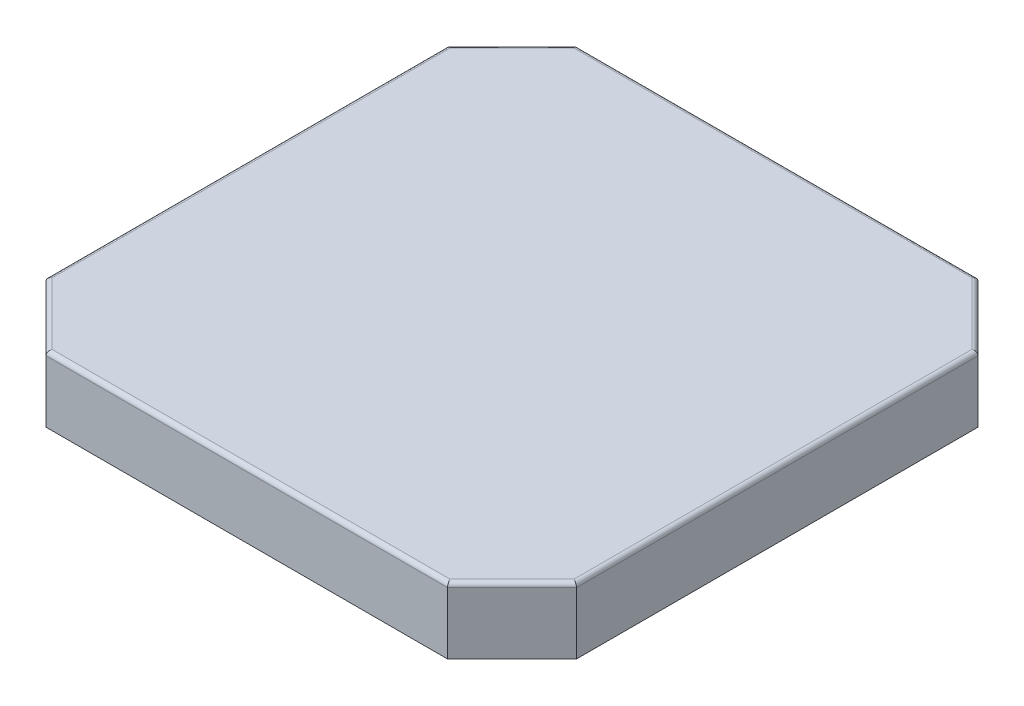
from build123d import *

# Parameters (mm, degrees)
ESQUISSE1_W             = 24.7
ESQUISSE1_H             = 24.7
BOSS_EXTRU_1_DEPTH      = 3.08
CHANFREIN1_SIZE         = 3
CONG_1_R                = 0.2
ESQUISSE2_W             = 6
ESQUISSE2_H             = 2.88
ENL_V_MAT_EXTRU_1_DEPTH = 22.08
ENL_V_MAT_EXTRU_2_DEPTH = 2.88


with BuildPart() as part:
    # Esquisse1 → Boss.-Extru.1 (new body)
    with BuildSketch(Plane(origin=(0, 0, 0), x_dir=(1, 0, 0), z_dir=(0, 1, 0))):
        with Locations((12.35, 12.35)):
            Rectangle(ESQUISSE1_W, ESQUISSE1_H)
    extrude(amount=BOSS_EXTRU_1_DEPTH)

    # Chanfrein1
    chanfrein1_edges = [part.edges().sort_by_distance(p)[0] for p in [
        (0, 1.54, -24.7),
        (24.7, 1.54, -24.7),
        (24.7, 1.54, 0),
        (0, 1.54, 0),
    ]]
    chamfer(chanfrein1_edges, length=CHANFREIN1_SIZE)

    # Congé1
    cong_1_edges = [part.edges().sort_by_distance(p)[0] for p in [
        (0, 3.08, -12.35),
        (12.35, 3.08, -24.7),
        (12.35, 3.08, 0),
        (24.7, 3.08, -12.35),
        (1.5, 3.08, -1.5),
        (23.2, 3.08, -1.5),
        (23.2, 3.08, -23.2),
        (1.5, 3.08, -23.2),
    ]]
    fillet(cong_1_edges, radius=CONG_1_R)

    # Esquisse2 → Enlèv. mat.-Extru.1 (cut)
    with BuildSketch(Plane(origin=(0, 0, -24.7), x_dir=(-1, 0, 0), z_dir=(0, 0, -1))):
        with Locations((-12.35, 1.44)):
            Rectangle(ESQUISSE2_W, ESQUISSE2_H)
    extrude(amount=-ENL_V_MAT_EXTRU_1_DEPTH, mode=Mode.SUBTRACT)

    # Esquisse3 → Enlèv. mat.-Extru.2 (cut)
    with BuildSketch(Plane.XZ):
        Polygon((3.124264069, -24.4), (21.575735931, -24.4), (24.4, -21.575735931), (24.4, -3.124264069), (21.575735931, -0.3), (3.124264069, -0.3), (0.3, -3.124264069), (0.3, -21.575735931), align=None)
    extrude(amount=-ENL_V_MAT_EXTRU_2_DEPTH, mode=Mode.SUBTRACT)


solid = part.part
